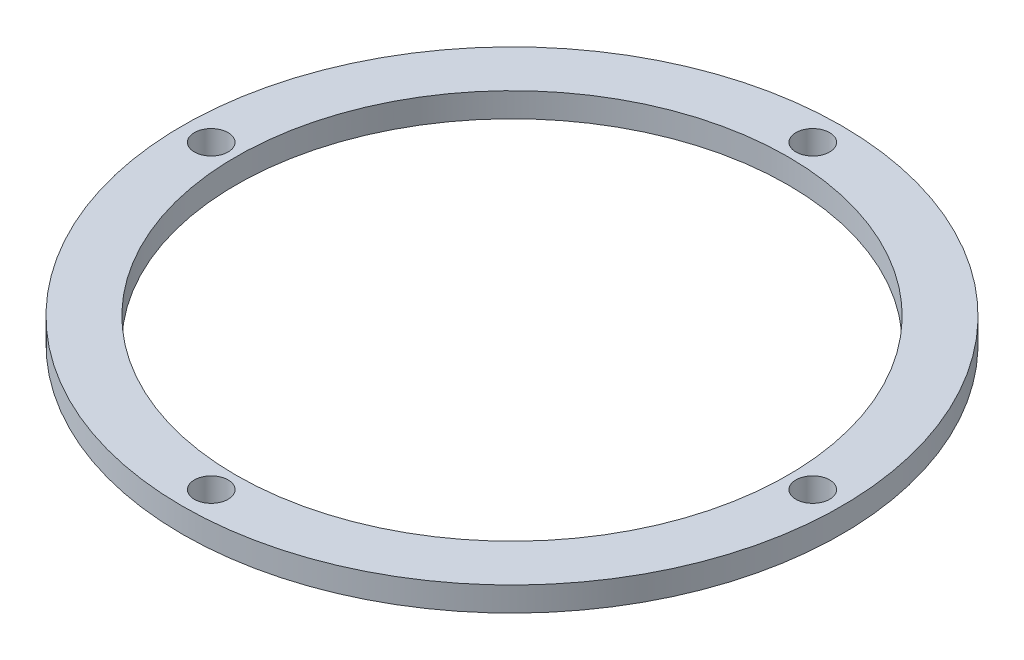
from build123d import *

# Parameters (mm, degrees)
SKETCH1_R           = 86
SKETCH1_R_2         = 72
SKETCH1_R_3         = 4.4
BOSS_EXTRUDE1_DEPTH = 6.35


with BuildPart() as part:
    # Sketch1 → Boss-Extrude1 (new body)
    with BuildSketch(Plane(origin=(0, 0, 0), x_dir=(1, 0, 0), z_dir=(0, 1, 0))):
        Circle(SKETCH1_R)
        Circle(SKETCH1_R_2, mode=Mode.SUBTRACT)
        with Locations((0, 78.4889)):
            Circle(SKETCH1_R_3, mode=Mode.SUBTRACT)
        with Locations((78.4889, 0)):
            Circle(SKETCH1_R_3, mode=Mode.SUBTRACT)
        with Locations((0, -78.4889)):
            Circle(SKETCH1_R_3, mode=Mode.SUBTRACT)
        with Locations((-78.4889, 0)):
            Circle(SKETCH1_R_3, mode=Mode.SUBTRACT)
    extrude(amount=BOSS_EXTRUDE1_DEPTH)


solid = part.part
